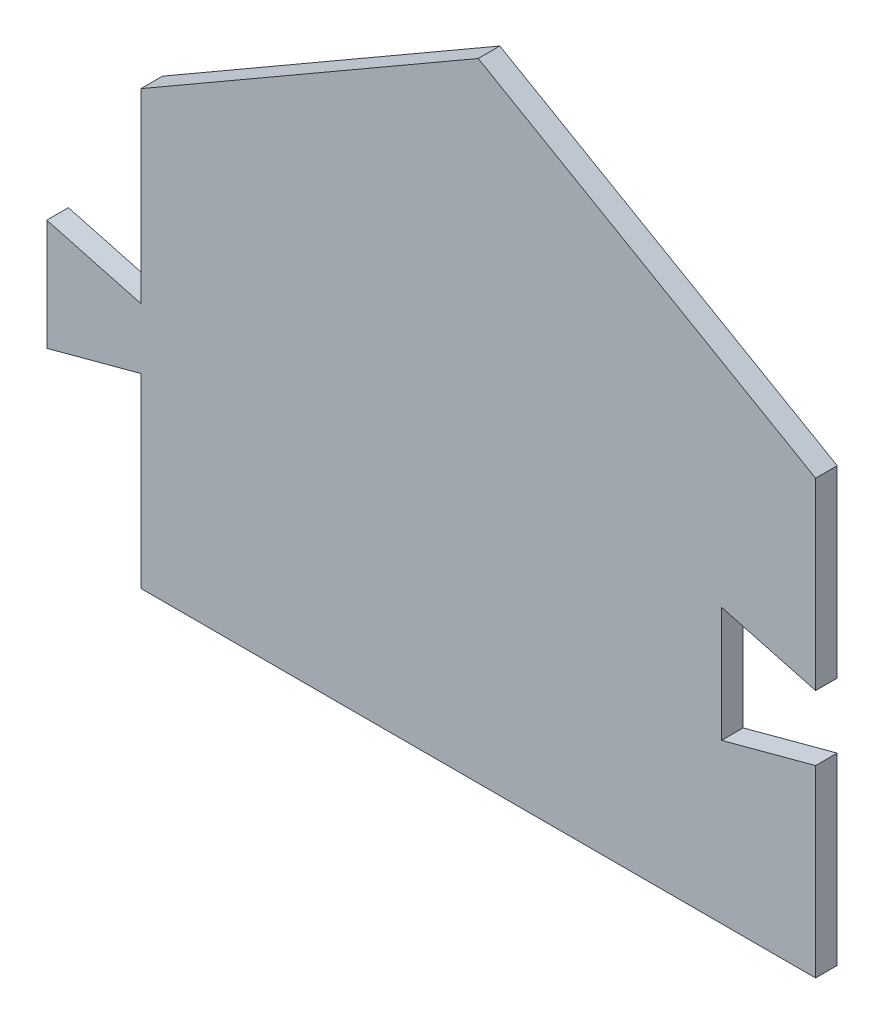
from build123d import *

# Parameters (mm, degrees)
BOSS_EXTRUDE1_DEPTH = 2.54


with BuildPart() as part:
    # Sketch1 → Boss-Extrude1 (new body)
    with BuildSketch(Plane.XY):
        Polygon((0, 0), (79.189362922, 0), (79.189362922, 21.59), (68.148830728, 18.631698314), (68.148830728, 32.168301686), (79.189362922, 29.21), (79.189362922, 50.8), (39.594681461, 73.66), (0, 50.8), (0, 28.956), (-11.040532194, 31.914301686), (-11.040532194, 18.885698314), (0, 21.844), align=None)
    extrude(amount=BOSS_EXTRUDE1_DEPTH)


solid = part.part
